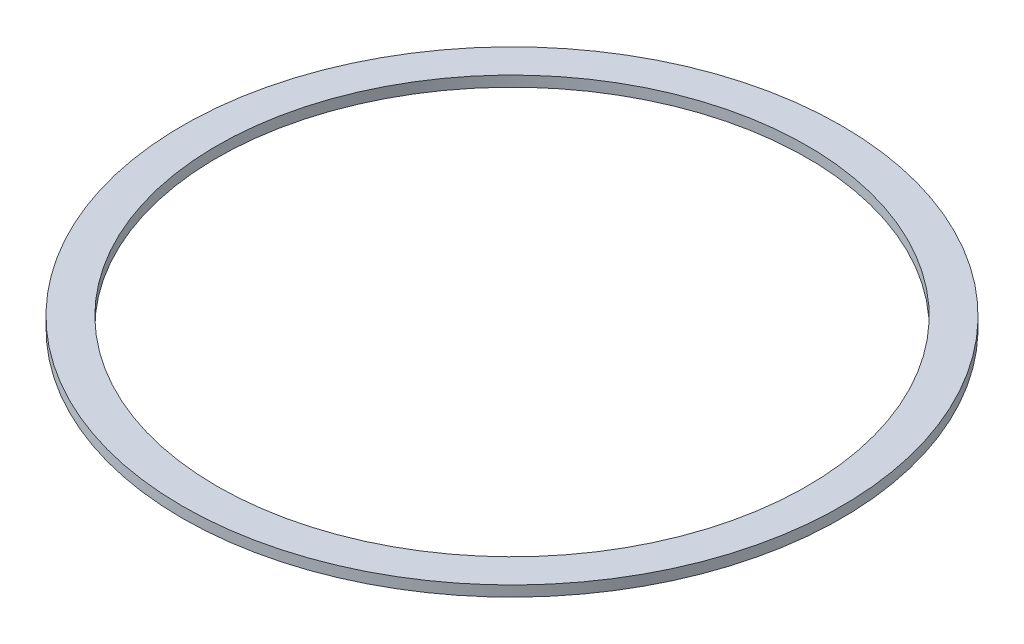
from build123d import *

# Parameters (mm, degrees)
SKETCH1_R           = 99.314
SKETCH1_R_2         = 88.9
BOSS_EXTRUDE1_DEPTH = 3.175


with BuildPart() as part:
    # Sketch1 → Boss-Extrude1 (new body)
    with BuildSketch(Plane(origin=(0, 0, 0), x_dir=(1, 0, 0), z_dir=(0, 1, 0))):
        Circle(SKETCH1_R)
        Circle(SKETCH1_R_2, mode=Mode.SUBTRACT)
    extrude(amount=BOSS_EXTRUDE1_DEPTH)


solid = part.part
